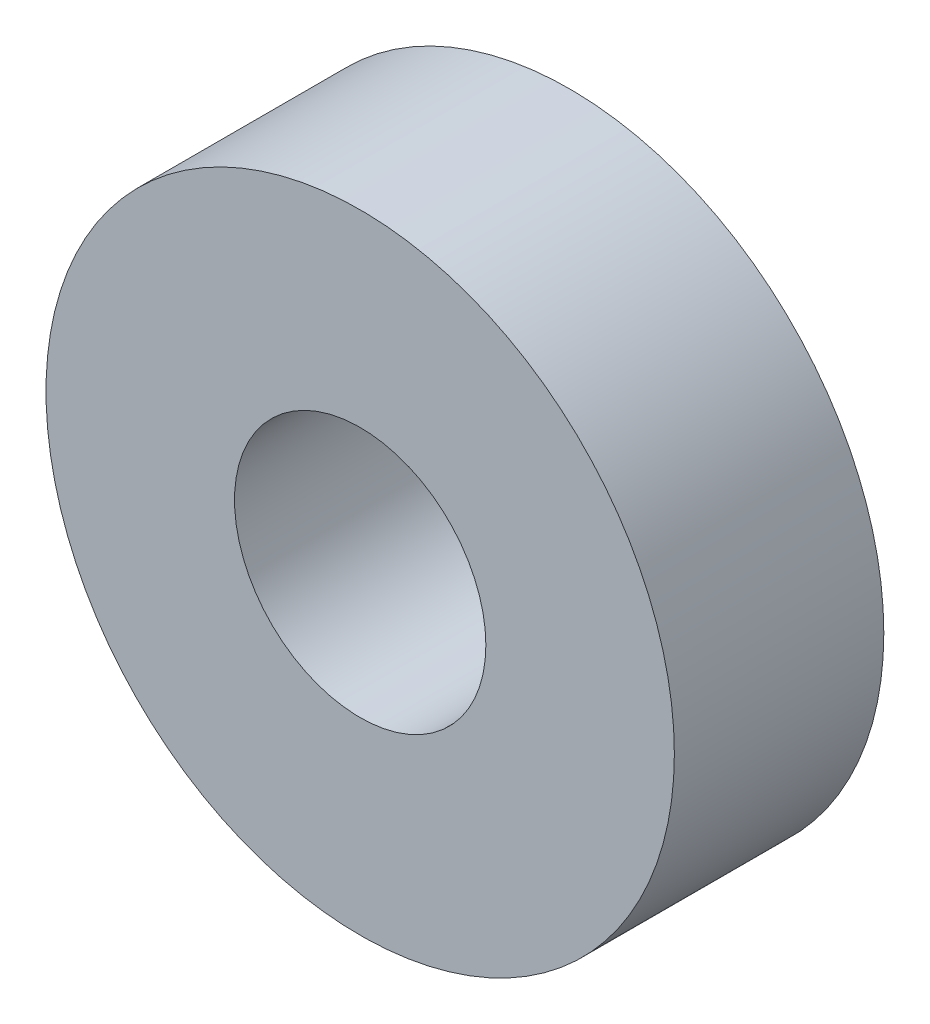
from build123d import *

# Parameters (mm, degrees)
SKETCH1_R           = 7.5
SKETCH1_R_2         = 3
BOSS_EXTRUDE1_DEPTH = 5


with BuildPart() as part:
    # Sketch1 → Boss-Extrude1 (new body)
    with BuildSketch(Plane.XY):
        Circle(SKETCH1_R)
        Circle(SKETCH1_R_2, mode=Mode.SUBTRACT)
    extrude(amount=BOSS_EXTRUDE1_DEPTH)


solid = part.part
